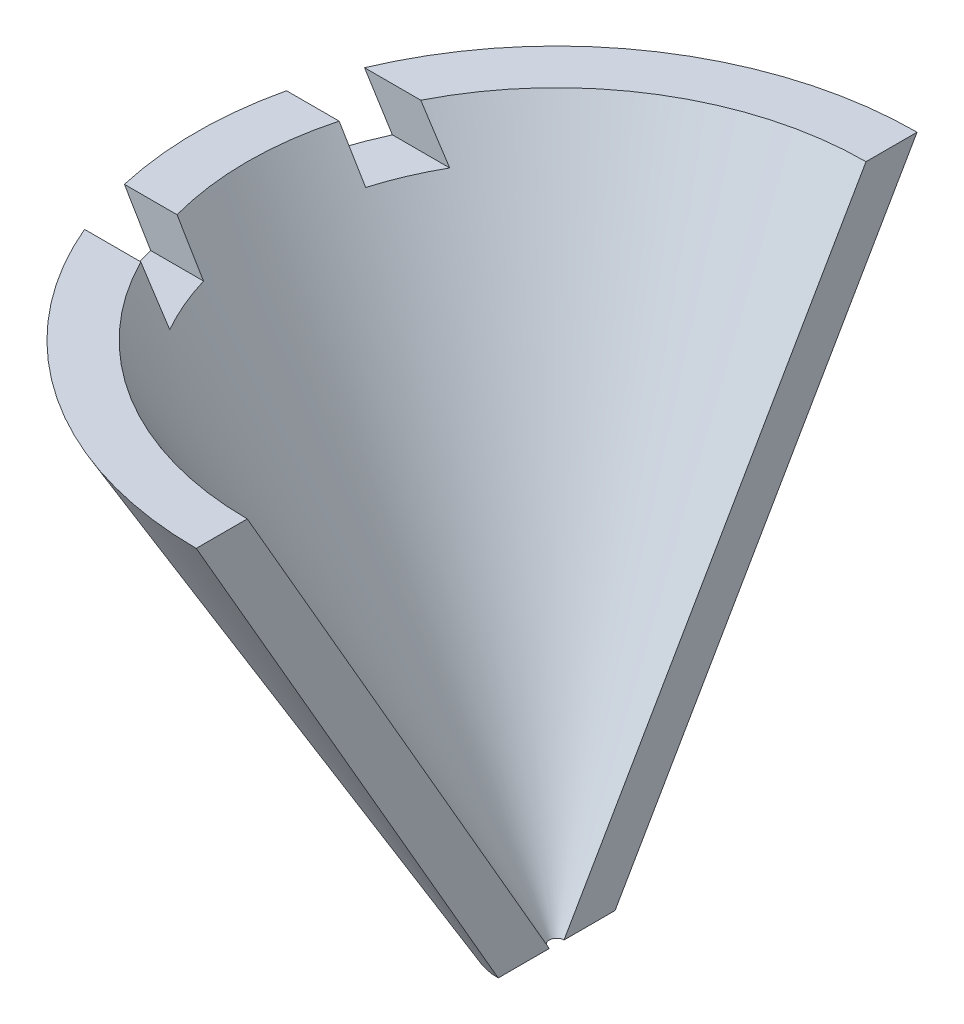
from build123d import *

# Parameters (mm, degrees)
REVOLVE_3_ANGLE           = 90
REVOLVE_3_OTHER_WAY_ANGLE = 90
SKETCH_4_W                = 6
SKETCH_4_H                = 1.5
CUT_EXTRUDE_1_DEPTH       = 2


with BuildPart() as part:
    # 草图2 → 旋转3 (revolve)
    with BuildSketch(Plane.XY):
        Polygon((-10.496621672, 4.324275584), (-12.22867248, 4.324275584), (-1.982050808, -13.423393759), (-0.25, -13.423393759), align=None)
    revolve(axis=Axis((0, 0, 0), (0, -1, 0)), revolution_arc=REVOLVE_3_ANGLE)

    # 草图2 → 旋转3 other way (revolve)
    with BuildSketch(Plane.XY):
        Polygon((-10.496621672, 4.324275584), (-12.22867248, 4.324275584), (-1.982050808, -13.423393759), (-0.25, -13.423393759), align=None)
    revolve(axis=Axis((0, 0, 0), (0, 1, 0)), revolution_arc=REVOLVE_3_OTHER_WAY_ANGLE)

    # 草图4 → 切除-拉伸1 (cut)
    with BuildSketch(Plane.XY.offset(2.75)):
        with Locations((-8.915449241, 3.574275584)):
            Rectangle(SKETCH_4_W, SKETCH_4_H)
    cut_extrude_1 = extrude(amount=CUT_EXTRUDE_1_DEPTH, mode=Mode.SUBTRACT)

    # 镜向1: 切除-拉伸1 across plane
    add(cut_extrude_1.mirror(Plane.XY), mode=Mode.SUBTRACT)


solid = part.part
